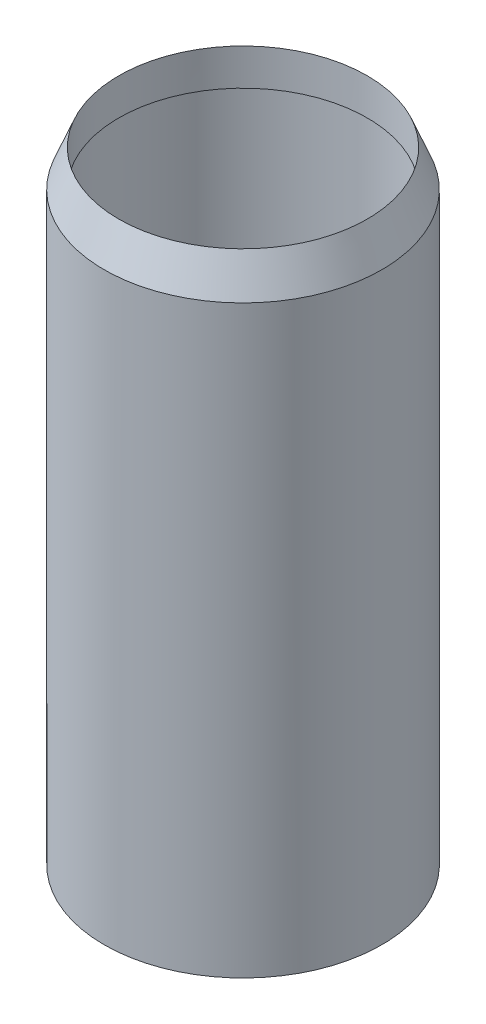
from build123d import *

# Parameters (mm, degrees)
SKETCH_1_R          = 19
SKETCH_1_R_2        = 17.5
EXTRUDE_1_DEPTH     = 80
SKETCH_3_R          = 19
SKETCH_2_R          = 17
SKETCH_4_R          = 17
CUT_EXTRUDE_1_DEPTH = 5


with BuildPart() as part:
    # Эскиз1 → Бобышка-Вытянуть1 (new body)
    with BuildSketch(Plane(origin=(0, 0, 0), x_dir=(1, 0, 0), z_dir=(0, 1, 0))):
        Circle(SKETCH_1_R)
        Circle(SKETCH_1_R_2, mode=Mode.SUBTRACT)
    extrude(amount=EXTRUDE_1_DEPTH)

    # Эскиз3 → По сечениям1 section 0
    with BuildSketch(Plane(origin=(0, 80, 0), x_dir=(1, 0, 0), z_dir=(0, 1, 0))):
        Circle(SKETCH_3_R)
    # Эскиз2 → По сечениям1 section 1
    with BuildSketch(Plane(origin=(0, 85, 0), x_dir=(1, 0, 0), z_dir=(0, 1, 0))):
        Circle(SKETCH_2_R)
    loft()

    # Эскиз4 → Вырез-Вытянуть1 (cut)
    with BuildSketch(Plane(origin=(0, 85, 0), x_dir=(1, 0, 0), z_dir=(0, 1, 0))):
        Circle(SKETCH_4_R)
    extrude(amount=-CUT_EXTRUDE_1_DEPTH, mode=Mode.SUBTRACT)


solid = part.part
